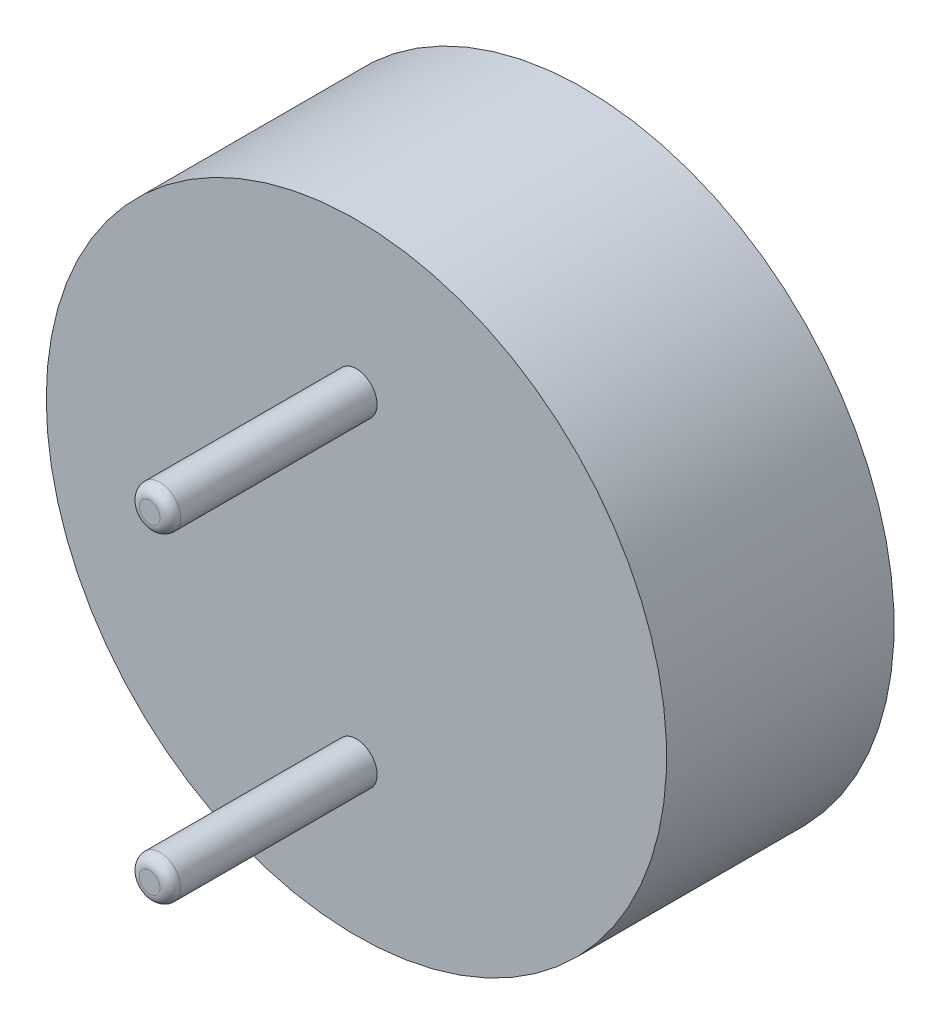
from build123d import *

# Parameters (mm, degrees)
FILLET1_R           = 10
SKETCH3_R           = 1
BOSS_EXTRUDE1_DEPTH = 10
FILLET2_R           = 0.5


with BuildPart() as part:
    # Sketch2 → Revolve1 (revolve)
    with BuildSketch(Plane(origin=(0, 0, 0), x_dir=(1, 0, 0), z_dir=(0, 1, 0))):
        with BuildLine():
            Line((0, -5.875), (15, -5.875))
            Line((15, -5.875), (15, 5.125))
            Line((15, 5.125), (12.5, 5.125))
            add(Edge.make_bspline(
                [(12.5, 5.125), (9.5, 5.875)],
                knots=[0, 0, 1, 1], degree=1))
            Line((9.5, 5.875), (0, 5.875))
            Line((0, 5.875), (0, -5.875))
        make_face()
    revolve(axis=Axis((0, 0, 0), (0, 0, 1)))

    # Fillet1
    fillet1_edges = [part.edges().sort_by_distance(p)[0] for p in [
        (-12.5, 0, -5.125),
        (-9.5, 0, -5.875),
    ]]
    fillet(fillet1_edges, radius=FILLET1_R)

    # Sketch3 → Boss-Extrude1 (add)
    with BuildSketch(Plane.XY.offset(5.875)):
        with Locations((0, 7.75)):
            Circle(SKETCH3_R)
        with Locations((0, -7.75)):
            Circle(SKETCH3_R)
    extrude(amount=BOSS_EXTRUDE1_DEPTH)

    # Fillet2
    fillet2_edges = [part.edges().sort_by_distance(p)[0] for p in [
        (-1, 7.75, 15.875),
        (-1, -7.75, 15.875),
    ]]
    fillet(fillet2_edges, radius=FILLET2_R)


solid = part.part
